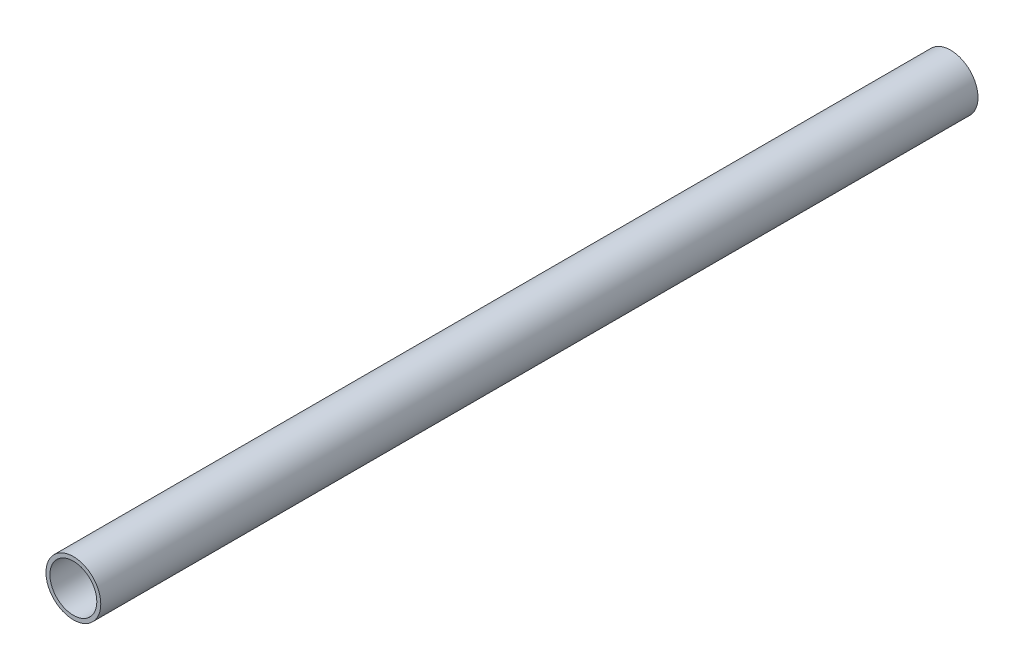
from build123d import *

# Parameters (mm, degrees)
SKETCH1_R           = 1.5875
SKETCH1_R_2         = 1.3589
EXTRUDE_THIN1_DEPTH = 50.8


with BuildPart() as part:
    # Sketch1 → Extrude-Thin1 (new body)
    with BuildSketch(Plane.XY):
        Circle(SKETCH1_R)
        Circle(SKETCH1_R_2, mode=Mode.SUBTRACT)
    extrude(amount=EXTRUDE_THIN1_DEPTH)


solid = part.part
